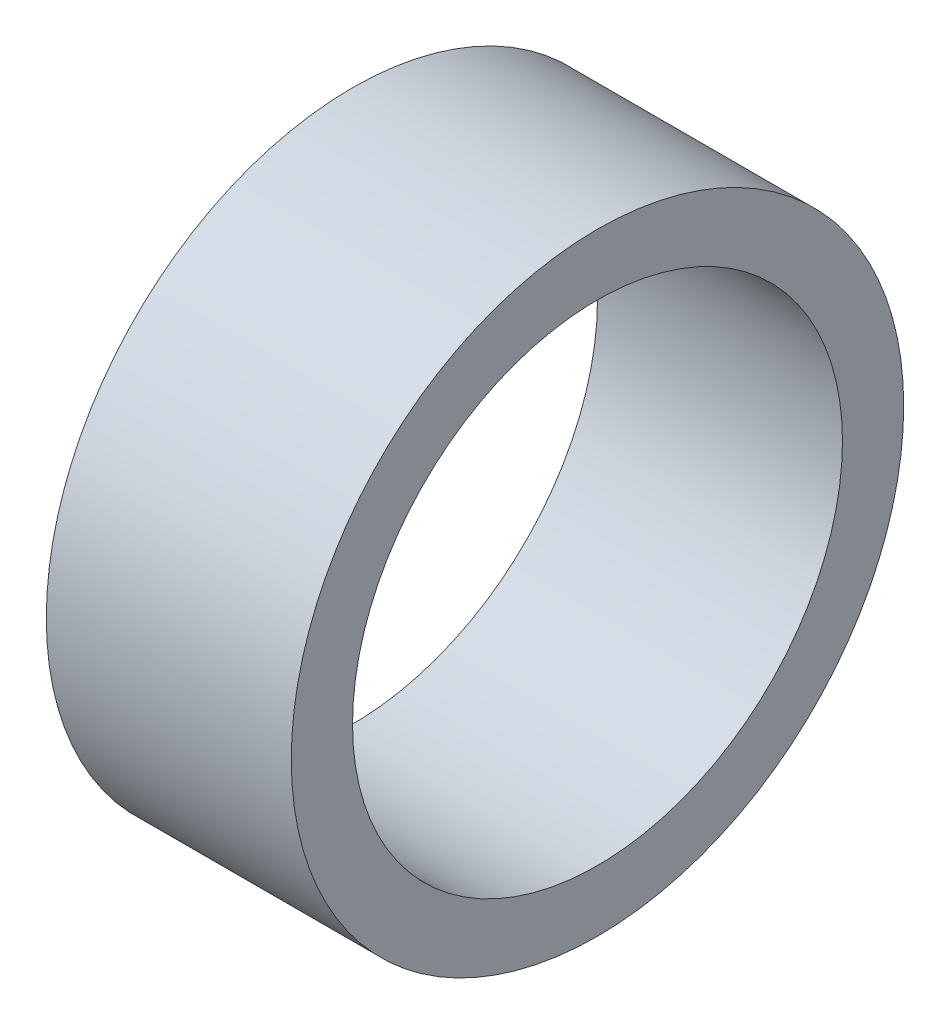
from build123d import *

# Parameters (mm, degrees)
SKETCH_1_R      = 6.25
SKETCH_1_R_2    = 5
EXTRUDE_1_DEPTH = 5


with BuildPart() as part:
    # 스케치1 → 보스-돌출1 (new body)
    with BuildSketch(Plane(origin=(0, 0, 0), x_dir=(0, 0, -1), z_dir=(1, 0, 0))):
        Circle(SKETCH_1_R)
        Circle(SKETCH_1_R_2, mode=Mode.SUBTRACT)
    extrude(amount=EXTRUDE_1_DEPTH)


solid = part.part
